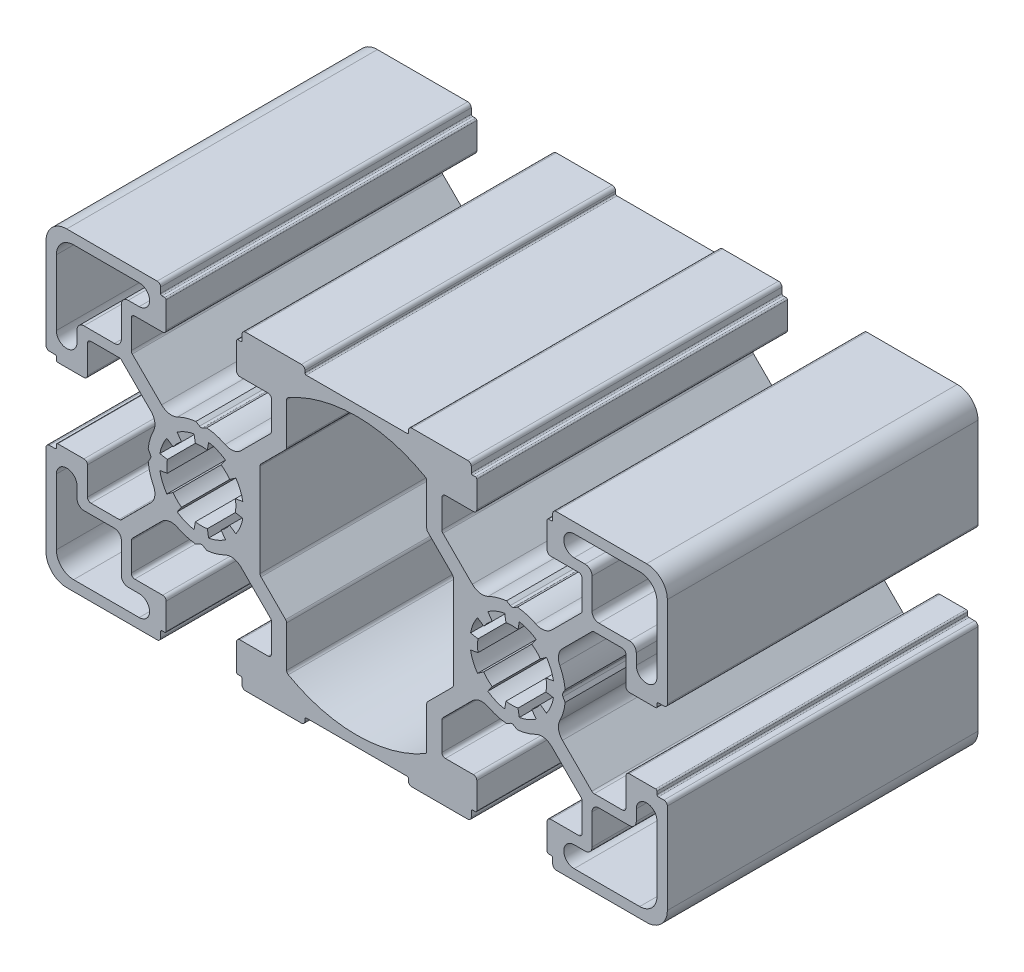
from build123d import *

# Parameters (mm, degrees)
EXTRUDE_1_DEPTH = 45


with BuildPart() as part:
    # Эскиз1 → Бобышка-Вытянуть1 (new body)
    with BuildSketch(Plane.XY):
        with BuildLine():
            Line((55.180223005, 50.12100939), (63.280223005, 50.12100939))
            ThreePointArc((63.280223005, 50.12100939), (63.633776395, 49.97456278), (63.780223005, 49.62100939))
            Line((63.780223005, 49.62100939), (63.780223005, 49.32100939))
            ThreePointArc((63.780223005, 49.32100939), (63.838801648, 49.179588033), (63.980223005, 49.12100939))
            Line((63.980223005, 49.12100939), (78.580223005, 49.12100939))
            ThreePointArc((78.580223005, 49.12100939), (78.721644361, 49.179588033), (78.780223005, 49.32100939))
            Line((78.780223005, 49.32100939), (78.780223005, 49.62100939))
            ThreePointArc((78.780223005, 49.62100939), (78.926669614, 49.97456278), (79.280223005, 50.12100939))
            Line((79.280223005, 50.12100939), (87.380223005, 50.12100939))
            ThreePointArc((87.380223005, 50.12100939), (87.733776395, 49.97456278), (87.880223005, 49.62100939))
            Line((87.880223005, 49.62100939), (87.880223005, 48.82100939))
            ThreePointArc((87.880223005, 48.82100939), (87.938801648, 48.679588033), (88.080223005, 48.62100939))
            Line((88.080223005, 48.62100939), (88.480223005, 48.62100939))
            ThreePointArc((88.480223005, 48.62100939), (88.621644361, 48.562430746), (88.680223005, 48.42100939))
            Line((88.680223005, 48.42100939), (88.680223005, 44.62100939))
            ThreePointArc((88.680223005, 44.62100939), (88.533776395, 44.267455999), (88.180223005, 44.12100939))
            Line((88.180223005, 44.12100939), (84.130223005, 44.12100939))
            ThreePointArc((84.130223005, 44.12100939), (83.776669614, 43.97456278), (83.630223005, 43.62100939))
            Line((83.630223005, 43.62100939), (83.630223005, 39.533751089))
            ThreePointArc((83.630223005, 39.533751089), (83.668283238, 39.342409373), (83.776669614, 39.180197699))
            Line((83.776669614, 39.180197699), (87.447989958, 35.508877355))
            Line((87.447989958, 35.508877355), (88.02790685, 34.928960463))
            ThreePointArc((88.02790685, 34.928960463), (89.11967342, 34.369338182), (90.332771259, 34.552436449))
            ThreePointArc((90.332771259, 34.552436449), (91.624370262, 35.05618952), (92.985109359, 35.321489823))
            Line((92.985109359, 35.321489823), (93.530223005, 35.006768313))
            ThreePointArc((93.530223005, 35.006768313), (93.780223005, 34.939781015), (94.030223005, 35.006768313))
            Line((94.030223005, 35.006768313), (94.57533665, 35.321489823))
            ThreePointArc((94.57533665, 35.321489823), (95.936075747, 35.05618952), (97.22767475, 34.552436449))
            ThreePointArc((97.22767475, 34.552436449), (98.440772589, 34.369338182), (99.53253916, 34.928960463))
            Line((99.53253916, 34.928960463), (100.112456052, 35.508877355))
            Line((100.112456052, 35.508877355), (103.783776395, 39.180197699))
            ThreePointArc((103.783776395, 39.180197699), (103.892162771, 39.342409373), (103.930223005, 39.533751089))
            Line((103.930223005, 39.533751089), (103.930223005, 43.62100939))
            ThreePointArc((103.930223005, 43.62100939), (103.783776395, 43.97456278), (103.430223005, 44.12100939))
            Line((103.430223005, 44.12100939), (99.380223005, 44.12100939))
            ThreePointArc((99.380223005, 44.12100939), (99.026669614, 44.267455999), (98.880223005, 44.62100939))
            Line((98.880223005, 44.62100939), (98.880223005, 48.42100939))
            ThreePointArc((98.880223005, 48.42100939), (98.938801648, 48.562430746), (99.080223005, 48.62100939))
            Line((99.080223005, 48.62100939), (99.480223005, 48.62100939))
            ThreePointArc((99.480223005, 48.62100939), (99.621644361, 48.679588033), (99.680223005, 48.82100939))
            Line((99.680223005, 48.82100939), (99.680223005, 49.62100939))
            ThreePointArc((99.680223005, 49.62100939), (99.826669614, 49.97456278), (100.180223005, 50.12100939))
            Line((100.180223005, 50.12100939), (113.280223005, 50.12100939))
            ThreePointArc((113.280223005, 50.12100939), (115.401543348, 49.242329733), (116.280223005, 47.12100939))
            Line((116.280223005, 47.12100939), (116.280223005, 34.02100939))
            ThreePointArc((116.280223005, 34.02100939), (116.133776395, 33.667455999), (115.780223005, 33.52100939))
            Line((115.780223005, 33.52100939), (114.980223005, 33.52100939))
            ThreePointArc((114.980223005, 33.52100939), (114.838801648, 33.462430746), (114.780223005, 33.32100939))
            Line((114.780223005, 33.32100939), (114.780223005, 32.92100939))
            ThreePointArc((114.780223005, 32.92100939), (114.721644361, 32.779588033), (114.580223005, 32.72100939))
            Line((114.580223005, 32.72100939), (110.780223005, 32.72100939))
            ThreePointArc((110.780223005, 32.72100939), (110.426669614, 32.867455999), (110.280223005, 33.22100939))
            Line((110.280223005, 33.22100939), (110.280223005, 37.27100939))
            ThreePointArc((110.280223005, 37.27100939), (110.133776395, 37.62456278), (109.780223005, 37.77100939))
            Line((109.780223005, 37.77100939), (105.692964704, 37.77100939))
            ThreePointArc((105.692964704, 37.77100939), (105.501622988, 37.732949156), (105.339411314, 37.62456278))
            Line((105.339411314, 37.62456278), (101.66809097, 33.953242437))
            Line((101.66809097, 33.953242437), (101.088174078, 33.373325545))
            ThreePointArc((101.088174078, 33.373325545), (100.528551797, 32.281558974), (100.711650064, 31.068461135))
            ThreePointArc((100.711650064, 31.068461135), (101.215403135, 29.776862132), (101.480703438, 28.416123035))
            Line((101.480703438, 28.416123035), (101.165981928, 27.87100939))
            ThreePointArc((101.165981928, 27.87100939), (101.09899463, 27.62100939), (101.165981928, 27.37100939))
            Line((101.165981928, 27.37100939), (101.480703438, 26.825895744))
            ThreePointArc((101.480703438, 26.825895744), (101.215403135, 25.465156647), (100.711650064, 24.173557644))
            ThreePointArc((100.711650064, 24.173557644), (100.528551797, 22.960459805), (101.088174078, 21.868693235))
            Line((101.088174078, 21.868693235), (101.66809097, 21.288776343))
            Line((101.66809097, 21.288776343), (105.339411314, 17.617455999))
            ThreePointArc((105.339411314, 17.617455999), (105.501622988, 17.509069623), (105.692964704, 17.47100939))
            Line((105.692964704, 17.47100939), (109.780223005, 17.47100939))
            ThreePointArc((109.780223005, 17.47100939), (110.133776395, 17.617455999), (110.280223005, 17.97100939))
            Line((110.280223005, 17.97100939), (110.280223005, 22.02100939))
            ThreePointArc((110.280223005, 22.02100939), (110.426669614, 22.37456278), (110.780223005, 22.52100939))
            Line((110.780223005, 22.52100939), (114.580223005, 22.52100939))
            ThreePointArc((114.580223005, 22.52100939), (114.721644361, 22.462430746), (114.780223005, 22.32100939))
            Line((114.780223005, 22.32100939), (114.780223005, 21.92100939))
            ThreePointArc((114.780223005, 21.92100939), (114.838801648, 21.779588033), (114.980223005, 21.72100939))
            Line((114.980223005, 21.72100939), (115.780223005, 21.72100939))
            ThreePointArc((115.780223005, 21.72100939), (116.133776395, 21.57456278), (116.280223005, 21.22100939))
            Line((116.280223005, 21.22100939), (116.280223005, 8.12100939))
            ThreePointArc((116.280223005, 8.12100939), (115.401543348, 5.999689046), (113.280223005, 5.12100939))
            Line((113.280223005, 5.12100939), (100.180223005, 5.12100939))
            ThreePointArc((100.180223005, 5.12100939), (99.826669614, 5.267455999), (99.680223005, 5.62100939))
            Line((99.680223005, 5.62100939), (99.680223005, 6.42100939))
            ThreePointArc((99.680223005, 6.42100939), (99.621644361, 6.562430746), (99.480223005, 6.62100939))
            Line((99.480223005, 6.62100939), (99.080223005, 6.62100939))
            ThreePointArc((99.080223005, 6.62100939), (98.938801648, 6.679588033), (98.880223005, 6.82100939))
            Line((98.880223005, 6.82100939), (98.880223005, 10.62100939))
            ThreePointArc((98.880223005, 10.62100939), (99.026669614, 10.97456278), (99.380223005, 11.12100939))
            Line((99.380223005, 11.12100939), (103.430223005, 11.12100939))
            ThreePointArc((103.430223005, 11.12100939), (103.783776395, 11.267455999), (103.930223005, 11.62100939))
            Line((103.930223005, 11.62100939), (103.930223005, 15.70826769))
            ThreePointArc((103.930223005, 15.70826769), (103.892162771, 15.899609406), (103.783776395, 16.06182108))
            Line((103.783776395, 16.06182108), (100.112456052, 19.733141424))
            Line((100.112456052, 19.733141424), (99.53253916, 20.313058316))
            ThreePointArc((99.53253916, 20.313058316), (98.440772589, 20.872680597), (97.22767475, 20.68958233))
            ThreePointArc((97.22767475, 20.68958233), (95.936075747, 20.185829259), (94.57533665, 19.920528956))
            Line((94.57533665, 19.920528956), (94.030223005, 20.235250466))
            ThreePointArc((94.030223005, 20.235250466), (93.780223005, 20.302237764), (93.530223005, 20.235250466))
            Line((93.530223005, 20.235250466), (92.985109359, 19.920528956))
            ThreePointArc((92.985109359, 19.920528956), (91.624370262, 20.185829259), (90.332771259, 20.68958233))
            ThreePointArc((90.332771259, 20.68958233), (89.11967342, 20.872680597), (88.02790685, 20.313058316))
            Line((88.02790685, 20.313058316), (87.447989958, 19.733141424))
            Line((87.447989958, 19.733141424), (83.776669614, 16.06182108))
            ThreePointArc((83.776669614, 16.06182108), (83.668283238, 15.899609406), (83.630223005, 15.70826769))
            Line((83.630223005, 15.70826769), (83.630223005, 11.62100939))
            ThreePointArc((83.630223005, 11.62100939), (83.776669614, 11.267455999), (84.130223005, 11.12100939))
            Line((84.130223005, 11.12100939), (88.180223005, 11.12100939))
            ThreePointArc((88.180223005, 11.12100939), (88.533776395, 10.97456278), (88.680223005, 10.62100939))
            Line((88.680223005, 10.62100939), (88.680223005, 6.82100939))
            ThreePointArc((88.680223005, 6.82100939), (88.621644361, 6.679588033), (88.480223005, 6.62100939))
            Line((88.480223005, 6.62100939), (88.080223005, 6.62100939))
            ThreePointArc((88.080223005, 6.62100939), (87.938801648, 6.562430746), (87.880223005, 6.42100939))
            Line((87.880223005, 6.42100939), (87.880223005, 5.62100939))
            ThreePointArc((87.880223005, 5.62100939), (87.733776395, 5.267455999), (87.380223005, 5.12100939))
            Line((87.380223005, 5.12100939), (79.280223005, 5.12100939))
            ThreePointArc((79.280223005, 5.12100939), (78.926669614, 5.267455999), (78.780223005, 5.62100939))
            Line((78.780223005, 5.62100939), (78.780223005, 5.92100939))
            ThreePointArc((78.780223005, 5.92100939), (78.721644361, 6.062430746), (78.580223005, 6.12100939))
            Line((78.580223005, 6.12100939), (63.980223005, 6.12100939))
            ThreePointArc((63.980223005, 6.12100939), (63.838801648, 6.062430746), (63.780223005, 5.92100939))
            Line((63.780223005, 5.92100939), (63.780223005, 5.62100939))
            ThreePointArc((63.780223005, 5.62100939), (63.633776395, 5.267455999), (63.280223005, 5.12100939))
            Line((63.280223005, 5.12100939), (55.180223005, 5.12100939))
            ThreePointArc((55.180223005, 5.12100939), (54.826669614, 5.267455999), (54.680223005, 5.62100939))
            Line((54.680223005, 5.62100939), (54.680223005, 6.42100939))
            ThreePointArc((54.680223005, 6.42100939), (54.621644361, 6.562430746), (54.480223005, 6.62100939))
            Line((54.480223005, 6.62100939), (54.080223005, 6.62100939))
            ThreePointArc((54.080223005, 6.62100939), (53.938801648, 6.679588033), (53.880223005, 6.82100939))
            Line((53.880223005, 6.82100939), (53.880223005, 10.62100939))
            ThreePointArc((53.880223005, 10.62100939), (54.026669614, 10.97456278), (54.380223005, 11.12100939))
            Line((54.380223005, 11.12100939), (58.430223005, 11.12100939))
            ThreePointArc((58.430223005, 11.12100939), (58.783776395, 11.267455999), (58.930223005, 11.62100939))
            Line((58.930223005, 11.62100939), (58.930223005, 15.70826769))
            ThreePointArc((58.930223005, 15.70826769), (58.892162771, 15.899609406), (58.783776395, 16.06182108))
            Line((58.783776395, 16.06182108), (55.112456052, 19.733141424))
            Line((55.112456052, 19.733141424), (54.53253916, 20.313058316))
            ThreePointArc((54.53253916, 20.313058316), (53.440772589, 20.872680597), (52.22767475, 20.68958233))
            ThreePointArc((52.22767475, 20.68958233), (50.936075747, 20.185829259), (49.57533665, 19.920528956))
            Line((49.57533665, 19.920528956), (49.030223005, 20.235250466))
            ThreePointArc((49.030223005, 20.235250466), (48.780223005, 20.302237764), (48.530223005, 20.235250466))
            Line((48.530223005, 20.235250466), (47.985109359, 19.920528956))
            ThreePointArc((47.985109359, 19.920528956), (46.624370262, 20.185829259), (45.332771259, 20.68958233))
            ThreePointArc((45.332771259, 20.68958233), (44.11967342, 20.872680597), (43.02790685, 20.313058316))
            Line((43.02790685, 20.313058316), (42.447989958, 19.733141424))
            Line((42.447989958, 19.733141424), (38.776669614, 16.06182108))
            ThreePointArc((38.776669614, 16.06182108), (38.668283238, 15.899609406), (38.630223005, 15.70826769))
            Line((38.630223005, 15.70826769), (38.630223005, 11.62100939))
            ThreePointArc((38.630223005, 11.62100939), (38.776669614, 11.267455999), (39.130223005, 11.12100939))
            Line((39.130223005, 11.12100939), (43.180223005, 11.12100939))
            ThreePointArc((43.180223005, 11.12100939), (43.533776395, 10.97456278), (43.680223005, 10.62100939))
            Line((43.680223005, 10.62100939), (43.680223005, 6.82100939))
            ThreePointArc((43.680223005, 6.82100939), (43.621644361, 6.679588033), (43.480223005, 6.62100939))
            Line((43.480223005, 6.62100939), (43.080223005, 6.62100939))
            ThreePointArc((43.080223005, 6.62100939), (42.938801648, 6.562430746), (42.880223005, 6.42100939))
            Line((42.880223005, 6.42100939), (42.880223005, 5.62100939))
            ThreePointArc((42.880223005, 5.62100939), (42.733776395, 5.267455999), (42.380223005, 5.12100939))
            Line((42.380223005, 5.12100939), (29.280223005, 5.12100939))
            ThreePointArc((29.280223005, 5.12100939), (27.158902661, 5.999689046), (26.280223005, 8.12100939))
            Line((26.280223005, 8.12100939), (26.280223005, 21.22100939))
            ThreePointArc((26.280223005, 21.22100939), (26.426669614, 21.57456278), (26.780223005, 21.72100939))
            Line((26.780223005, 21.72100939), (27.580223005, 21.72100939))
            ThreePointArc((27.580223005, 21.72100939), (27.721644361, 21.779588033), (27.780223005, 21.92100939))
            Line((27.780223005, 21.92100939), (27.780223005, 22.32100939))
            ThreePointArc((27.780223005, 22.32100939), (27.838801648, 22.462430746), (27.980223005, 22.52100939))
            Line((27.980223005, 22.52100939), (31.780223005, 22.52100939))
            ThreePointArc((31.780223005, 22.52100939), (32.133776395, 22.37456278), (32.280223005, 22.02100939))
            Line((32.280223005, 22.02100939), (32.280223005, 17.97100939))
            ThreePointArc((32.280223005, 17.97100939), (32.426669614, 17.617455999), (32.780223005, 17.47100939))
            Line((32.780223005, 17.47100939), (36.867481305, 17.47100939))
            ThreePointArc((36.867481305, 17.47100939), (37.058823021, 17.509069623), (37.221034695, 17.617455999))
            Line((37.221034695, 17.617455999), (40.892355039, 21.288776343))
            Line((40.892355039, 21.288776343), (41.472271931, 21.868693235))
            ThreePointArc((41.472271931, 21.868693235), (42.031894212, 22.960459805), (41.848795945, 24.173557644))
            ThreePointArc((41.848795945, 24.173557644), (41.345042875, 25.465156647), (41.079742571, 26.825895744))
            Line((41.079742571, 26.825895744), (41.394464081, 27.37100939))
            ThreePointArc((41.394464081, 27.37100939), (41.461451379, 27.62100939), (41.394464081, 27.87100939))
            Line((41.394464081, 27.87100939), (41.079742571, 28.416123035))
            ThreePointArc((41.079742571, 28.416123035), (41.345042875, 29.776862132), (41.848795945, 31.068461135))
            ThreePointArc((41.848795945, 31.068461135), (42.031894212, 32.281558974), (41.472271931, 33.373325545))
            Line((41.472271931, 33.373325545), (40.892355039, 33.953242437))
            Line((40.892355039, 33.953242437), (37.221034695, 37.62456278))
            ThreePointArc((37.221034695, 37.62456278), (37.058823021, 37.732949156), (36.867481305, 37.77100939))
            Line((36.867481305, 37.77100939), (32.780223005, 37.77100939))
            ThreePointArc((32.780223005, 37.77100939), (32.426669614, 37.62456278), (32.280223005, 37.27100939))
            Line((32.280223005, 37.27100939), (32.280223005, 33.22100939))
            ThreePointArc((32.280223005, 33.22100939), (32.133776395, 32.867455999), (31.780223005, 32.72100939))
            Line((31.780223005, 32.72100939), (27.980223005, 32.72100939))
            ThreePointArc((27.980223005, 32.72100939), (27.838801648, 32.779588033), (27.780223005, 32.92100939))
            Line((27.780223005, 32.92100939), (27.780223005, 33.32100939))
            ThreePointArc((27.780223005, 33.32100939), (27.721644361, 33.462430746), (27.580223005, 33.52100939))
            Line((27.580223005, 33.52100939), (26.780223005, 33.52100939))
            ThreePointArc((26.780223005, 33.52100939), (26.426669614, 33.667455999), (26.280223005, 34.02100939))
            Line((26.280223005, 34.02100939), (26.280223005, 47.12100939))
            ThreePointArc((26.280223005, 47.12100939), (27.158902661, 49.242329733), (29.280223005, 50.12100939))
            Line((29.280223005, 50.12100939), (42.380223005, 50.12100939))
            ThreePointArc((42.380223005, 50.12100939), (42.733776395, 49.97456278), (42.880223005, 49.62100939))
            Line((42.880223005, 49.62100939), (42.880223005, 48.82100939))
            ThreePointArc((42.880223005, 48.82100939), (42.938801648, 48.679588033), (43.080223005, 48.62100939))
            Line((43.080223005, 48.62100939), (43.480223005, 48.62100939))
            ThreePointArc((43.480223005, 48.62100939), (43.621644361, 48.562430746), (43.680223005, 48.42100939))
            Line((43.680223005, 48.42100939), (43.680223005, 44.62100939))
            ThreePointArc((43.680223005, 44.62100939), (43.533776395, 44.267455999), (43.180223005, 44.12100939))
            Line((43.180223005, 44.12100939), (39.130223005, 44.12100939))
            ThreePointArc((39.130223005, 44.12100939), (38.776669614, 43.97456278), (38.630223005, 43.62100939))
            Line((38.630223005, 43.62100939), (38.630223005, 39.533751089))
            ThreePointArc((38.630223005, 39.533751089), (38.668283238, 39.342409373), (38.776669614, 39.180197699))
            Line((38.776669614, 39.180197699), (42.447989958, 35.508877355))
            Line((42.447989958, 35.508877355), (43.02790685, 34.928960463))
            ThreePointArc((43.02790685, 34.928960463), (44.11967342, 34.369338182), (45.332771259, 34.552436449))
            ThreePointArc((45.332771259, 34.552436449), (46.624370262, 35.05618952), (47.985109359, 35.321489823))
            Line((47.985109359, 35.321489823), (48.530223005, 35.006768313))
            ThreePointArc((48.530223005, 35.006768313), (48.780223005, 34.939781015), (49.030223005, 35.006768313))
            Line((49.030223005, 35.006768313), (49.57533665, 35.321489823))
            ThreePointArc((49.57533665, 35.321489823), (50.936075747, 35.05618952), (52.22767475, 34.552436449))
            ThreePointArc((52.22767475, 34.552436449), (53.440772589, 34.369338182), (54.53253916, 34.928960463))
            Line((54.53253916, 34.928960463), (55.112456052, 35.508877355))
            Line((55.112456052, 35.508877355), (58.783776395, 39.180197699))
            ThreePointArc((58.783776395, 39.180197699), (58.892162771, 39.342409373), (58.930223005, 39.533751089))
            Line((58.930223005, 39.533751089), (58.930223005, 43.62100939))
            ThreePointArc((58.930223005, 43.62100939), (58.783776395, 43.97456278), (58.430223005, 44.12100939))
            Line((58.430223005, 44.12100939), (54.380223005, 44.12100939))
            ThreePointArc((54.380223005, 44.12100939), (54.026669614, 44.267455999), (53.880223005, 44.62100939))
            Line((53.880223005, 44.62100939), (53.880223005, 48.42100939))
            ThreePointArc((53.880223005, 48.42100939), (53.938801648, 48.562430746), (54.080223005, 48.62100939))
            Line((54.080223005, 48.62100939), (54.480223005, 48.62100939))
            ThreePointArc((54.480223005, 48.62100939), (54.621644361, 48.679588033), (54.680223005, 48.82100939))
            Line((54.680223005, 48.82100939), (54.680223005, 49.62100939))
            ThreePointArc((54.680223005, 49.62100939), (54.826669614, 49.97456278), (55.180223005, 50.12100939))
        make_face()
        with BuildLine():
            Line((61.130223005, 38.622481252), (61.130223005, 41.387377757))
            Line((61.130223005, 41.387377757), (61.130223005, 44.565846361))
            ThreePointArc((61.130223005, 44.565846361), (61.197951129, 44.817125142), (61.382787107, 45.000329361))
            ThreePointArc((61.382787107, 45.000329361), (71.280223005, 47.62100939), (81.177658902, 45.000329361))
            ThreePointArc((81.177658902, 45.000329361), (81.36249488, 44.817125142), (81.430223005, 44.565846361))
            Line((81.430223005, 44.565846361), (81.430223005, 41.387377757))
            Line((81.430223005, 41.387377757), (81.430223005, 38.622481252))
            ThreePointArc((81.430223005, 38.622481252), (81.468283238, 38.431139536), (81.576669614, 38.268927862))
            Line((81.576669614, 38.268927862), (85.133776395, 34.71182108))
            ThreePointArc((85.133776395, 34.71182108), (85.242162771, 34.549609406), (85.280223005, 34.35826769))
            Line((85.280223005, 34.35826769), (85.280223005, 20.883751089))
            ThreePointArc((85.280223005, 20.883751089), (85.242162771, 20.692409373), (85.133776395, 20.530197699))
            Line((85.133776395, 20.530197699), (81.576669614, 16.973090918))
            ThreePointArc((81.576669614, 16.973090918), (81.468283238, 16.810879243), (81.430223005, 16.619537527))
            Line((81.430223005, 16.619537527), (81.430223005, 13.854641023))
            Line((81.430223005, 13.854641023), (81.430223005, 10.676172418))
            ThreePointArc((81.430223005, 10.676172418), (81.36249488, 10.424893637), (81.177658902, 10.241689419))
            ThreePointArc((81.177658902, 10.241689419), (71.280223005, 7.62100939), (61.382787107, 10.241689419))
            ThreePointArc((61.382787107, 10.241689419), (61.197951129, 10.424893637), (61.130223005, 10.676172418))
            Line((61.130223005, 10.676172418), (61.130223005, 13.854641023))
            Line((61.130223005, 13.854641023), (61.130223005, 16.619537527))
            ThreePointArc((61.130223005, 16.619537527), (61.092162771, 16.810879243), (60.983776395, 16.973090918))
            Line((60.983776395, 16.973090918), (57.426669614, 20.530197699))
            ThreePointArc((57.426669614, 20.530197699), (57.318283238, 20.692409373), (57.280223005, 20.883751089))
            Line((57.280223005, 20.883751089), (57.280223005, 34.35826769))
            ThreePointArc((57.280223005, 34.35826769), (57.318283238, 34.549609406), (57.426669614, 34.71182108))
            Line((57.426669614, 34.71182108), (60.983776395, 38.268927862))
            ThreePointArc((60.983776395, 38.268927862), (61.092162771, 38.431139536), (61.130223005, 38.622481252))
        make_face(mode=Mode.SUBTRACT)
        with BuildLine():
            Line((37.190223005, 42.29676611), (37.190223005, 40.21100939))
            ThreePointArc((37.190223005, 40.21100939), (36.897329786, 39.503902608), (36.190223005, 39.21100939))
            Line((36.190223005, 39.21100939), (34.104466284, 39.21100939))
            Line((34.104466284, 39.21100939), (31.780223005, 39.21100939))
            ThreePointArc((31.780223005, 39.21100939), (31.073116224, 38.918116171), (30.780223005, 38.21100939))
            Line((30.780223005, 38.21100939), (30.780223005, 36.62100939))
            ThreePointArc((30.780223005, 36.62100939), (29.280223005, 35.12100939), (27.780223005, 36.62100939))
            Line((27.780223005, 36.62100939), (27.780223005, 46.12100939))
            ThreePointArc((27.780223005, 46.12100939), (28.512456052, 47.888776343), (30.280223005, 48.62100939))
            Line((30.280223005, 48.62100939), (39.780223005, 48.62100939))
            ThreePointArc((39.780223005, 48.62100939), (41.280223005, 47.12100939), (39.780223005, 45.62100939))
            Line((39.780223005, 45.62100939), (38.190223005, 45.62100939))
            ThreePointArc((38.190223005, 45.62100939), (37.483116224, 45.328116171), (37.190223005, 44.62100939))
            Line((37.190223005, 44.62100939), (37.190223005, 42.29676611))
        make_face(mode=Mode.SUBTRACT)
        with BuildLine():
            Line((90.912340823, 23.525249168), (90.281406743, 22.62418192))
            ThreePointArc((90.281406743, 22.62418192), (91.445854067, 21.985344241), (92.720969121, 21.613682096))
            Line((92.720969121, 21.613682096), (92.911982116, 22.696970625))
            ThreePointArc((92.911982116, 22.696970625), (93.780223005, 22.62100939), (94.648463893, 22.696970625))
            Line((94.648463893, 22.696970625), (94.839476888, 21.613682096))
            ThreePointArc((94.839476888, 21.613682096), (96.114591942, 21.985344241), (97.279039266, 22.62418192))
            Line((97.279039266, 22.62418192), (96.648105186, 23.525249168))
            ThreePointArc((96.648105186, 23.525249168), (97.315756911, 24.085475484), (97.875983226, 24.753127208))
            Line((97.875983226, 24.753127208), (98.777050475, 24.122193128))
            ThreePointArc((98.777050475, 24.122193128), (99.415888153, 25.286640452), (99.787550298, 26.561755506))
            Line((99.787550298, 26.561755506), (98.70426177, 26.752768501))
            ThreePointArc((98.70426177, 26.752768501), (98.780223005, 27.62100939), (98.70426177, 28.489250278))
            Line((98.70426177, 28.489250278), (99.787550298, 28.680263273))
            ThreePointArc((99.787550298, 28.680263273), (99.415888153, 29.955378327), (98.777050475, 31.119825651))
            Line((98.777050475, 31.119825651), (97.875983226, 30.488891571))
            ThreePointArc((97.875983226, 30.488891571), (97.315756911, 31.156543296), (96.648105186, 31.716769611))
            Line((96.648105186, 31.716769611), (97.279039266, 32.61783686))
            ThreePointArc((97.279039266, 32.61783686), (96.114591942, 33.256674538), (94.839476888, 33.628336683))
            Line((94.839476888, 33.628336683), (94.648463893, 32.545048155))
            ThreePointArc((94.648463893, 32.545048155), (93.780223005, 32.62100939), (92.911982116, 32.545048155))
            Line((92.911982116, 32.545048155), (92.720969121, 33.628336683))
            ThreePointArc((92.720969121, 33.628336683), (91.445854067, 33.256674538), (90.281406743, 32.61783686))
            Line((90.281406743, 32.61783686), (90.912340823, 31.716769611))
            ThreePointArc((90.912340823, 31.716769611), (90.244689099, 31.156543296), (89.684462783, 30.488891571))
            Line((89.684462783, 30.488891571), (88.783395535, 31.119825651))
            ThreePointArc((88.783395535, 31.119825651), (88.144557856, 29.955378327), (87.772895711, 28.680263273))
            Line((87.772895711, 28.680263273), (88.85618424, 28.489250278))
            ThreePointArc((88.85618424, 28.489250278), (88.780223005, 27.62100939), (88.85618424, 26.752768501))
            Line((88.85618424, 26.752768501), (87.772895711, 26.561755506))
            ThreePointArc((87.772895711, 26.561755506), (88.144557856, 25.286640452), (88.783395535, 24.122193128))
            Line((88.783395535, 24.122193128), (89.684462783, 24.753127208))
            ThreePointArc((89.684462783, 24.753127208), (90.244689099, 24.085475484), (90.912340823, 23.525249168))
        make_face(mode=Mode.SUBTRACT)
        with BuildLine():
            Line((45.912340823, 31.716769611), (45.281406743, 32.61783686))
            ThreePointArc((45.281406743, 32.61783686), (46.445854067, 33.256674538), (47.720969121, 33.628336683))
            Line((47.720969121, 33.628336683), (47.911982116, 32.545048155))
            ThreePointArc((47.911982116, 32.545048155), (48.780223005, 32.62100939), (49.648463893, 32.545048155))
            Line((49.648463893, 32.545048155), (49.839476888, 33.628336683))
            ThreePointArc((49.839476888, 33.628336683), (51.114591942, 33.256674538), (52.279039266, 32.61783686))
            Line((52.279039266, 32.61783686), (51.648105186, 31.716769611))
            ThreePointArc((51.648105186, 31.716769611), (52.315756911, 31.156543296), (52.875983226, 30.488891571))
            Line((52.875983226, 30.488891571), (53.777050475, 31.119825651))
            ThreePointArc((53.777050475, 31.119825651), (54.415888153, 29.955378327), (54.787550298, 28.680263273))
            Line((54.787550298, 28.680263273), (53.70426177, 28.489250278))
            ThreePointArc((53.70426177, 28.489250278), (53.780223005, 27.62100939), (53.70426177, 26.752768501))
            Line((53.70426177, 26.752768501), (54.787550298, 26.561755506))
            ThreePointArc((54.787550298, 26.561755506), (54.415888153, 25.286640452), (53.777050475, 24.122193128))
            Line((53.777050475, 24.122193128), (52.875983226, 24.753127208))
            ThreePointArc((52.875983226, 24.753127208), (52.315756911, 24.085475484), (51.648105186, 23.525249168))
            Line((51.648105186, 23.525249168), (52.279039266, 22.62418192))
            ThreePointArc((52.279039266, 22.62418192), (51.114591942, 21.985344241), (49.839476888, 21.613682096))
            Line((49.839476888, 21.613682096), (49.648463893, 22.696970625))
            ThreePointArc((49.648463893, 22.696970625), (48.780223005, 22.62100939), (47.911982116, 22.696970625))
            Line((47.911982116, 22.696970625), (47.720969121, 21.613682096))
            ThreePointArc((47.720969121, 21.613682096), (46.445854067, 21.985344241), (45.281406743, 22.62418192))
            Line((45.281406743, 22.62418192), (45.912340823, 23.525249168))
            ThreePointArc((45.912340823, 23.525249168), (45.244689099, 24.085475484), (44.684462783, 24.753127208))
            Line((44.684462783, 24.753127208), (43.783395535, 24.122193128))
            ThreePointArc((43.783395535, 24.122193128), (43.144557856, 25.286640452), (42.772895711, 26.561755506))
            Line((42.772895711, 26.561755506), (43.85618424, 26.752768501))
            ThreePointArc((43.85618424, 26.752768501), (43.780223005, 27.62100939), (43.85618424, 28.489250278))
            Line((43.85618424, 28.489250278), (42.772895711, 28.680263273))
            ThreePointArc((42.772895711, 28.680263273), (43.144557856, 29.955378327), (43.783395535, 31.119825651))
            Line((43.783395535, 31.119825651), (44.684462783, 30.488891571))
            ThreePointArc((44.684462783, 30.488891571), (45.244689099, 31.156543296), (45.912340823, 31.716769611))
        make_face(mode=Mode.SUBTRACT)
        with BuildLine():
            Line((30.280223005, 6.62100939), (39.780223005, 6.62100939))
            ThreePointArc((39.780223005, 6.62100939), (41.280223005, 8.12100939), (39.780223005, 9.62100939))
            Line((39.780223005, 9.62100939), (38.190223005, 9.62100939))
            ThreePointArc((38.190223005, 9.62100939), (37.483116224, 9.913902608), (37.190223005, 10.62100939))
            Line((37.190223005, 10.62100939), (37.190223005, 12.945252669))
            Line((37.190223005, 12.945252669), (37.190223005, 15.03100939))
            ThreePointArc((37.190223005, 15.03100939), (36.897329786, 15.738116171), (36.190223005, 16.03100939))
            Line((36.190223005, 16.03100939), (34.104466284, 16.03100939))
            Line((34.104466284, 16.03100939), (31.780223005, 16.03100939))
            ThreePointArc((31.780223005, 16.03100939), (31.073116224, 16.323902608), (30.780223005, 17.03100939))
            Line((30.780223005, 17.03100939), (30.780223005, 18.62100939))
            ThreePointArc((30.780223005, 18.62100939), (29.280223005, 20.12100939), (27.780223005, 18.62100939))
            Line((27.780223005, 18.62100939), (27.780223005, 9.12100939))
            ThreePointArc((27.780223005, 9.12100939), (28.512456052, 7.353242437), (30.280223005, 6.62100939))
        make_face(mode=Mode.SUBTRACT)
        with BuildLine():
            Line((105.370223005, 12.945252669), (105.370223005, 15.03100939))
            ThreePointArc((105.370223005, 15.03100939), (105.663116224, 15.738116171), (106.370223005, 16.03100939))
            Line((106.370223005, 16.03100939), (108.455979725, 16.03100939))
            Line((108.455979725, 16.03100939), (110.780223005, 16.03100939))
            ThreePointArc((110.780223005, 16.03100939), (111.487329786, 16.323902608), (111.780223005, 17.03100939))
            Line((111.780223005, 17.03100939), (111.780223005, 18.62100939))
            ThreePointArc((111.780223005, 18.62100939), (113.280223005, 20.12100939), (114.780223005, 18.62100939))
            Line((114.780223005, 18.62100939), (114.780223005, 9.12100939))
            ThreePointArc((114.780223005, 9.12100939), (114.047989958, 7.353242437), (112.280223005, 6.62100939))
            Line((112.280223005, 6.62100939), (102.780223005, 6.62100939))
            ThreePointArc((102.780223005, 6.62100939), (101.280223005, 8.12100939), (102.780223005, 9.62100939))
            Line((102.780223005, 9.62100939), (104.370223005, 9.62100939))
            ThreePointArc((104.370223005, 9.62100939), (105.077329786, 9.913902608), (105.370223005, 10.62100939))
            Line((105.370223005, 10.62100939), (105.370223005, 12.945252669))
        make_face(mode=Mode.SUBTRACT)
        with BuildLine():
            Line((112.280223005, 48.62100939), (102.780223005, 48.62100939))
            ThreePointArc((102.780223005, 48.62100939), (101.280223005, 47.12100939), (102.780223005, 45.62100939))
            Line((102.780223005, 45.62100939), (104.370223005, 45.62100939))
            ThreePointArc((104.370223005, 45.62100939), (105.077329786, 45.328116171), (105.370223005, 44.62100939))
            Line((105.370223005, 44.62100939), (105.370223005, 42.29676611))
            Line((105.370223005, 42.29676611), (105.370223005, 40.21100939))
            ThreePointArc((105.370223005, 40.21100939), (105.663116224, 39.503902608), (106.370223005, 39.21100939))
            Line((106.370223005, 39.21100939), (108.455979725, 39.21100939))
            Line((108.455979725, 39.21100939), (110.780223005, 39.21100939))
            ThreePointArc((110.780223005, 39.21100939), (111.487329786, 38.918116171), (111.780223005, 38.21100939))
            Line((111.780223005, 38.21100939), (111.780223005, 36.62100939))
            ThreePointArc((111.780223005, 36.62100939), (113.280223005, 35.12100939), (114.780223005, 36.62100939))
            Line((114.780223005, 36.62100939), (114.780223005, 46.12100939))
            ThreePointArc((114.780223005, 46.12100939), (114.047989958, 47.888776343), (112.280223005, 48.62100939))
        make_face(mode=Mode.SUBTRACT)
    extrude(amount=EXTRUDE_1_DEPTH)


solid = part.part
